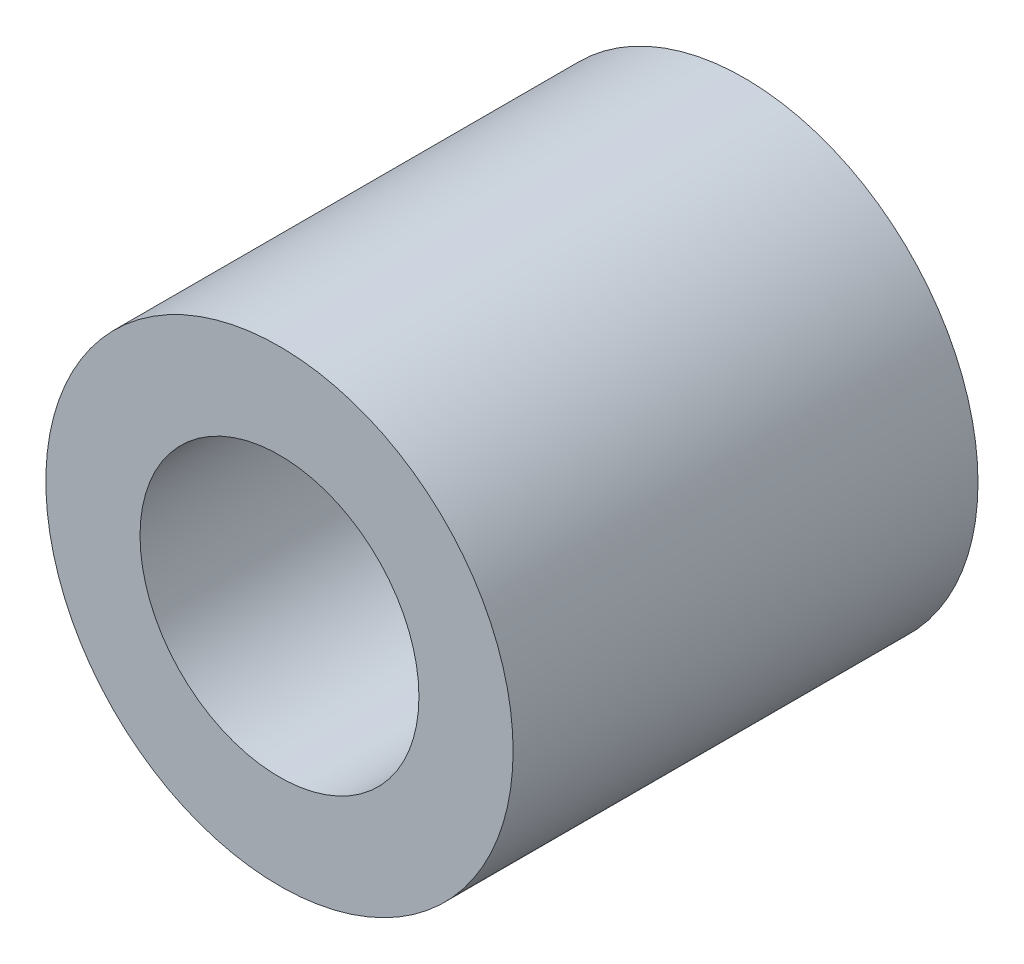
from build123d import *

# Parameters (mm, degrees)
SKETCH3_R                = 5.0255
SKETCH3_R_2              = 3
BOSS_EXTRUDE1_DEPTH      = 5
BOSS_EXTRUDE1_DEPTH_BACK = 5


with BuildPart() as part:
    # Sketch3 → Boss-Extrude1 (new body, two sides)
    with BuildSketch(Plane.XY) as boss_extrude1_sk:
        Circle(SKETCH3_R)
        Circle(SKETCH3_R_2, mode=Mode.SUBTRACT)
    extrude(amount=BOSS_EXTRUDE1_DEPTH)
    extrude(boss_extrude1_sk.sketch, amount=-BOSS_EXTRUDE1_DEPTH_BACK)


solid = part.part
